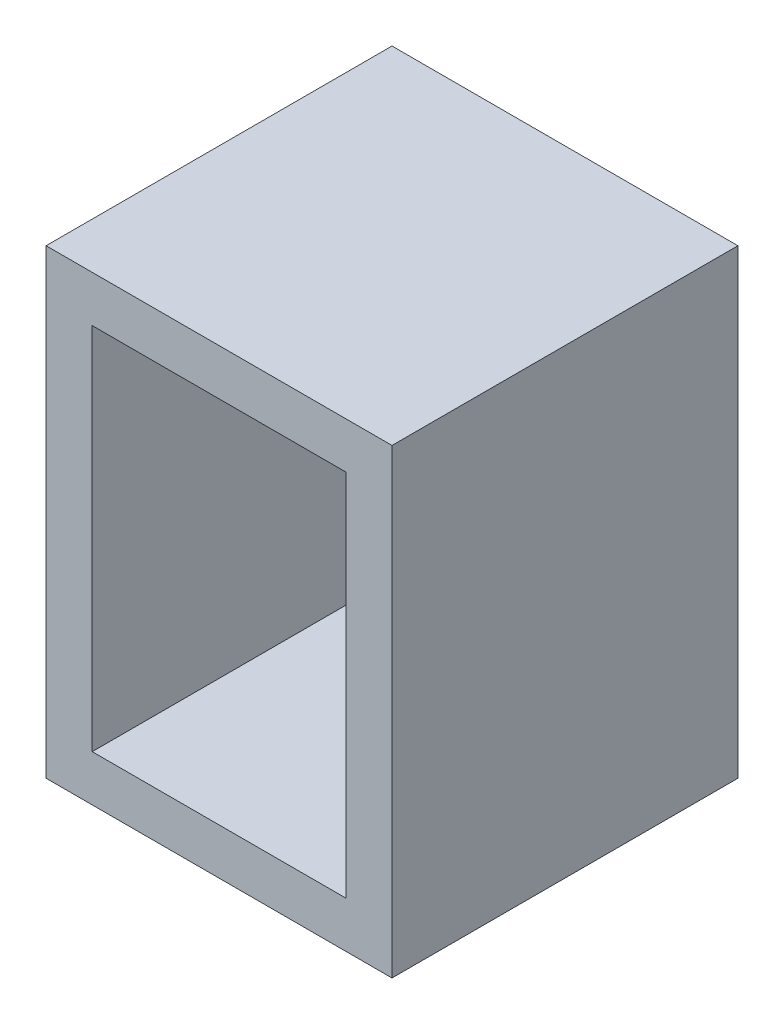
from build123d import *

# Parameters (mm, degrees)
SKETCH_1_W      = 150
SKETCH_1_H      = 150
EXTRUDE_1_DEPTH = 200
SHELL_1_T       = -20


with BuildPart() as part:
    # 草图1 → 凸台-拉伸1 (new body)
    with BuildSketch(Plane(origin=(0, 0, 0), x_dir=(1, 0, 0), z_dir=(0, 1, 0))):
        Rectangle(SKETCH_1_W, SKETCH_1_H)
    extrude(amount=EXTRUDE_1_DEPTH)

    # 抽壳1
    shell_1_openings = [part.faces().sort_by_distance(p)[0] for p in [
        (0, 100, 75),
    ]]
    offset(amount=SHELL_1_T, openings=shell_1_openings, kind=Kind.INTERSECTION)


solid = part.part
